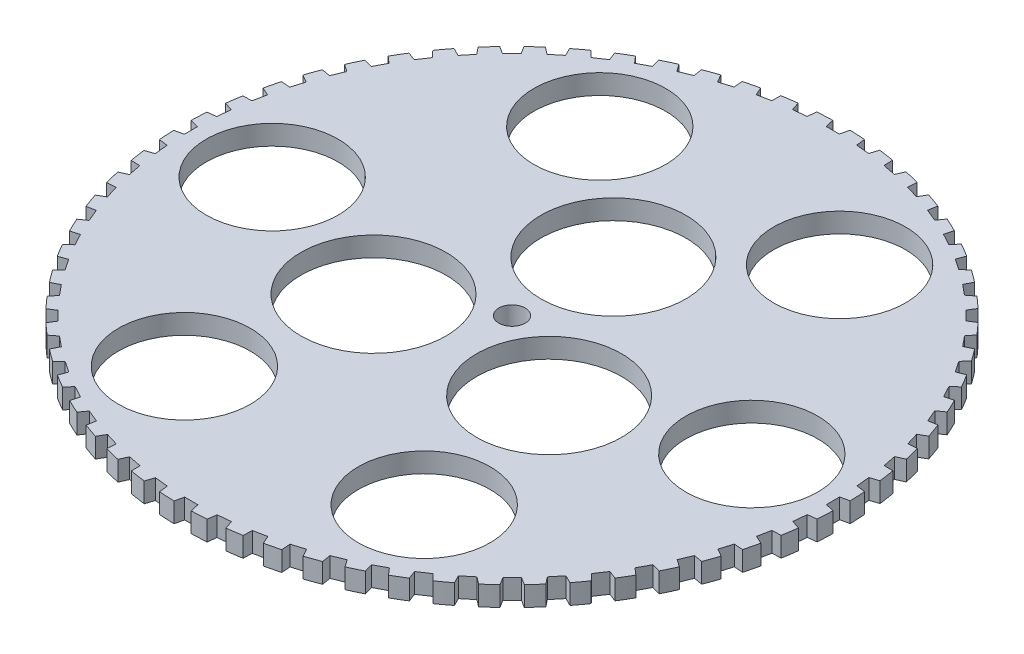
from build123d import *

# Parameters (mm, degrees)
ESQUISSE1_R             = 50
ESQUISSE1_R_2           = 10
ESQUISSE1_R_3           = 11
ESQUISSE1_R_4           = 2
EXTRUSION1_DEPTH        = 3
ENL_V_MAT_EXTRU_1_DEPTH = 3


with BuildPart() as part:
    # Esquisse1 → Extrusion1 (new body)
    with BuildSketch(Plane(origin=(0, 0, 0), x_dir=(1, 0, 0), z_dir=(0, 1, 0))):
        Circle(ESQUISSE1_R)
        with Locations((36.377671233, 0)):
            Circle(ESQUISSE1_R_2, mode=Mode.SUBTRACT)
        with Locations((18.188835616, -31.503987418)):
            Circle(ESQUISSE1_R_2, mode=Mode.SUBTRACT)
        with Locations((-18.188835616, -31.503987418)):
            Circle(ESQUISSE1_R_2, mode=Mode.SUBTRACT)
        with Locations((-36.377671233, 0)):
            Circle(ESQUISSE1_R_2, mode=Mode.SUBTRACT)
        with Locations((-18.188835616, 31.503987418)):
            Circle(ESQUISSE1_R_2, mode=Mode.SUBTRACT)
        with Locations((18.188835616, 31.503987418)):
            Circle(ESQUISSE1_R_2, mode=Mode.SUBTRACT)
        with Locations((0, 15.379178082)):
            Circle(ESQUISSE1_R_3, mode=Mode.SUBTRACT)
        with Locations((13.318758909, -7.689589041)):
            Circle(ESQUISSE1_R_3, mode=Mode.SUBTRACT)
        with Locations((-13.318758909, -7.689589041)):
            Circle(ESQUISSE1_R_3, mode=Mode.SUBTRACT)
        Circle(ESQUISSE1_R_4, mode=Mode.SUBTRACT)
    extrude(amount=EXTRUSION1_DEPTH)

    # Esquisse3 → Enlèv. mat.-Extru.1 (cut)
    with BuildSketch(Plane(origin=(0, 3, 0), x_dir=(1, 0, 0), z_dir=(0, 1, 0))):
        Polygon((-3.453309741, -50.942491879), (-6.512462802, -50.641191601), (-5.748220594, -48.341035297), (-3.753619852, -48.537486323), align=None)
        Polygon((1.021960462, -48.671684144), (-0.9822913, -48.671684144), (-1.51739873, -51.035673402), (1.556556265, -51.035673402), align=None)
        Polygon((-8.429918486, -50.358706311), (-11.444808297, -49.759007441), (-10.458791381, -47.544835855), (-8.493050754, -47.935845976), align=None)
        Polygon((-13.325342507, -49.289938873), (-16.266934032, -48.397616839), (-15.06863829, -46.290753652), (-13.150688935, -46.872557228), align=None)
        Polygon((-18.092436196, -47.746482378), (-20.9324003, -46.57013073), (-19.533365974, -44.590866187), (-17.681678793, -45.357860131), align=None)
        Polygon((-22.685289834, -45.743201157), (-25.39627611, -44.294148804), (-23.809976667, -42.461544305), (-22.042384418, -43.406342045), align=None)
        Polygon((-27.05967173, -43.299387904), (-29.615571898, -41.591590011), (-27.857284268, -39.923294539), (-26.190809832, -41.036797157), align=None)
        Polygon((-31.173454195, -40.438577875), (-33.549653539, -38.488481471), (-31.636310993, -37.000561622), (-30.08700343, -38.27204548), align=None)
        Polygon((-34.987019255, -37.188322235), (-37.160633677, -35.014707813), (-35.110662749, -33.72149307), (-33.693442737, -35.138713083), align=None)
        Polygon((-38.463640193, -33.579922723), (-40.413736598, -31.203723379), (-38.24687963, -30.117668106), (-36.975395772, -31.66697567), align=None)
        Polygon((-41.56983525, -29.648130198), (-43.277633143, -27.092230031), (-41.014758152, -26.223793535), (-39.901255533, -27.89026797), align=None)
        Polygon((-44.27569007, -25.430809972), (-45.724742423, -22.719823697), (-43.387642132, -22.077369496), (-42.442844391, -23.844961744), align=None)
        Polygon((-46.55514579, -20.968577145), (-47.731497438, -18.128613041), (-45.3426794, -17.71832832), (-44.575685456, -19.570015501), align=None)
        Polygon((-48.386250007, -16.304405457), (-49.27857204, -13.362813932), (-46.861041878, -13.188649956), (-46.279238302, -15.106599311), align=None)
        Polygon((-49.751368185, -11.483213431), (-50.351067055, -8.468323619), (-47.928106907, -8.531957684), (-47.537096785, -10.497698311), align=None)
        Polygon((-50.637353491, -6.551431783), (-50.938653769, -3.492278721), (-48.533598066, -3.793097996), (-48.337147039, -5.787698738), align=None)
        Polygon((-51.035673402, -1.556556265), (-51.035673402, 1.51739873), (-48.671684144, 0.9822913), (-48.671684144, -1.021960462), align=None)
        Polygon((-50.942491879, 3.453309741), (-50.641191601, 6.512462802), (-48.341035297, 5.748220594), (-48.537486323, 3.753619852), align=None)
        Polygon((-50.358706311, 8.429918486), (-49.759007441, 11.444808297), (-47.544835855, 10.458791381), (-47.935845976, 8.493050754), align=None)
        Polygon((-49.289938873, 13.325342507), (-48.397616839, 16.266934032), (-46.290753652, 15.06863829), (-46.872557228, 13.150688935), align=None)
        Polygon((-47.746482378, 18.092436196), (-46.57013073, 20.9324003), (-44.590866187, 19.533365974), (-45.357860131, 17.681678793), align=None)
        Polygon((-45.743201157, 22.685289834), (-44.294148804, 25.39627611), (-42.461544305, 23.809976667), (-43.406342045, 22.042384418), align=None)
        Polygon((-43.299387904, 27.05967173), (-41.591590011, 29.615571898), (-39.923294539, 27.857284268), (-41.036797157, 26.190809832), align=None)
        Polygon((-40.438577875, 31.173454195), (-38.488481471, 33.549653539), (-37.000561622, 31.636310993), (-38.27204548, 30.08700343), align=None)
        Polygon((-37.188322235, 34.987019255), (-35.014707813, 37.160633677), (-33.72149307, 35.110662749), (-35.138713083, 33.693442737), align=None)
        Polygon((-33.579922723, 38.463640193), (-31.203723379, 40.413736598), (-30.117668106, 38.24687963), (-31.66697567, 36.975395772), align=None)
        Polygon((-29.648130198, 41.56983525), (-27.092230031, 43.277633143), (-26.223793535, 41.014758152), (-27.89026797, 39.901255533), align=None)
        Polygon((-25.430809972, 44.27569007), (-22.719823697, 45.724742423), (-22.077369496, 43.387642132), (-23.844961744, 42.442844391), align=None)
        Polygon((-20.968577145, 46.55514579), (-18.128613041, 47.731497438), (-17.71832832, 45.3426794), (-19.570015501, 44.575685456), align=None)
        Polygon((-16.304405457, 48.386250007), (-13.362813932, 49.27857204), (-13.188649956, 46.861041878), (-15.106599311, 46.279238302), align=None)
        Polygon((-11.483213431, 49.751368185), (-8.468323619, 50.351067055), (-8.531957684, 47.928106907), (-10.497698311, 47.537096785), align=None)
        Polygon((-6.551431783, 50.637353491), (-3.492278721, 50.938653769), (-3.793097996, 48.533598066), (-5.787698738, 48.337147039), align=None)
        Polygon((-1.556556265, 51.035673402), (1.51739873, 51.035673402), (0.9822913, 48.671684144), (-1.021960462, 48.671684144), align=None)
        Polygon((3.453309741, 50.942491879), (6.512462802, 50.641191601), (5.748220594, 48.341035297), (3.753619852, 48.537486323), align=None)
        Polygon((8.429918486, 50.358706311), (11.444808297, 49.759007441), (10.458791381, 47.544835855), (8.493050754, 47.935845976), align=None)
        Polygon((13.325342507, 49.289938873), (16.266934032, 48.397616839), (15.06863829, 46.290753652), (13.150688935, 46.872557228), align=None)
        Polygon((18.092436196, 47.746482378), (20.9324003, 46.57013073), (19.533365974, 44.590866187), (17.681678793, 45.357860131), align=None)
        Polygon((22.685289834, 45.743201157), (25.39627611, 44.294148804), (23.809976667, 42.461544305), (22.042384418, 43.406342045), align=None)
        Polygon((27.05967173, 43.299387904), (29.615571898, 41.591590011), (27.857284268, 39.923294539), (26.190809832, 41.036797157), align=None)
        Polygon((31.173454195, 40.438577875), (33.549653539, 38.488481471), (31.636310993, 37.000561622), (30.08700343, 38.27204548), align=None)
        Polygon((34.987019255, 37.188322235), (37.160633677, 35.014707813), (35.110662749, 33.72149307), (33.693442737, 35.138713083), align=None)
        Polygon((38.463640193, 33.579922723), (40.413736598, 31.203723379), (38.24687963, 30.117668106), (36.975395772, 31.66697567), align=None)
        Polygon((41.56983525, 29.648130198), (43.277633143, 27.092230031), (41.014758152, 26.223793535), (39.901255533, 27.89026797), align=None)
        Polygon((44.27569007, 25.430809972), (45.724742423, 22.719823697), (43.387642132, 22.077369496), (42.442844391, 23.844961744), align=None)
        Polygon((46.55514579, 20.968577145), (47.731497438, 18.128613041), (45.3426794, 17.71832832), (44.575685456, 19.570015501), align=None)
        Polygon((48.386250007, 16.304405457), (49.27857204, 13.362813932), (46.861041878, 13.188649956), (46.279238302, 15.106599311), align=None)
        Polygon((49.751368185, 11.483213431), (50.351067055, 8.468323619), (47.928106907, 8.531957684), (47.537096785, 10.497698311), align=None)
        Polygon((50.637353491, 6.551431783), (50.938653769, 3.492278721), (48.533598066, 3.793097996), (48.337147039, 5.787698738), align=None)
        Polygon((51.035673402, 1.556556265), (51.035673402, -1.51739873), (48.671684144, -0.9822913), (48.671684144, 1.021960462), align=None)
        Polygon((50.942491879, -3.453309741), (50.641191601, -6.512462802), (48.341035297, -5.748220594), (48.537486323, -3.753619852), align=None)
        Polygon((50.358706311, -8.429918486), (49.759007441, -11.444808297), (47.544835855, -10.458791381), (47.935845976, -8.493050754), align=None)
        Polygon((49.289938873, -13.325342507), (48.397616839, -16.266934032), (46.290753652, -15.06863829), (46.872557228, -13.150688935), align=None)
        Polygon((47.746482378, -18.092436196), (46.57013073, -20.9324003), (44.590866187, -19.533365974), (45.357860131, -17.681678793), align=None)
        Polygon((45.743201157, -22.685289834), (44.294148804, -25.39627611), (42.461544305, -23.809976667), (43.406342045, -22.042384418), align=None)
        Polygon((43.299387904, -27.05967173), (41.591590011, -29.615571898), (39.923294539, -27.857284268), (41.036797157, -26.190809832), align=None)
        Polygon((40.438577875, -31.173454195), (38.488481471, -33.549653539), (37.000561622, -31.636310993), (38.27204548, -30.08700343), align=None)
        Polygon((37.188322235, -34.987019255), (35.014707813, -37.160633677), (33.72149307, -35.110662749), (35.138713083, -33.693442737), align=None)
        Polygon((33.579922723, -38.463640193), (31.203723379, -40.413736598), (30.117668106, -38.24687963), (31.66697567, -36.975395772), align=None)
        Polygon((29.648130198, -41.56983525), (27.092230031, -43.277633143), (26.223793535, -41.014758152), (27.89026797, -39.901255533), align=None)
        Polygon((25.430809972, -44.27569007), (22.719823697, -45.724742423), (22.077369496, -43.387642132), (23.844961744, -42.442844391), align=None)
        Polygon((20.968577145, -46.55514579), (18.128613041, -47.731497438), (17.71832832, -45.3426794), (19.570015501, -44.575685456), align=None)
        Polygon((16.304405457, -48.386250007), (13.362813932, -49.27857204), (13.188649956, -46.861041878), (15.106599311, -46.279238302), align=None)
        Polygon((11.483213431, -49.751368185), (8.468323619, -50.351067055), (8.531957684, -47.928106907), (10.497698311, -47.537096785), align=None)
        Polygon((6.551431783, -50.637353491), (3.492278721, -50.938653769), (3.793097996, -48.533598066), (5.787698738, -48.337147039), align=None)
    extrude(amount=-ENL_V_MAT_EXTRU_1_DEPTH, mode=Mode.SUBTRACT)


solid = part.part
